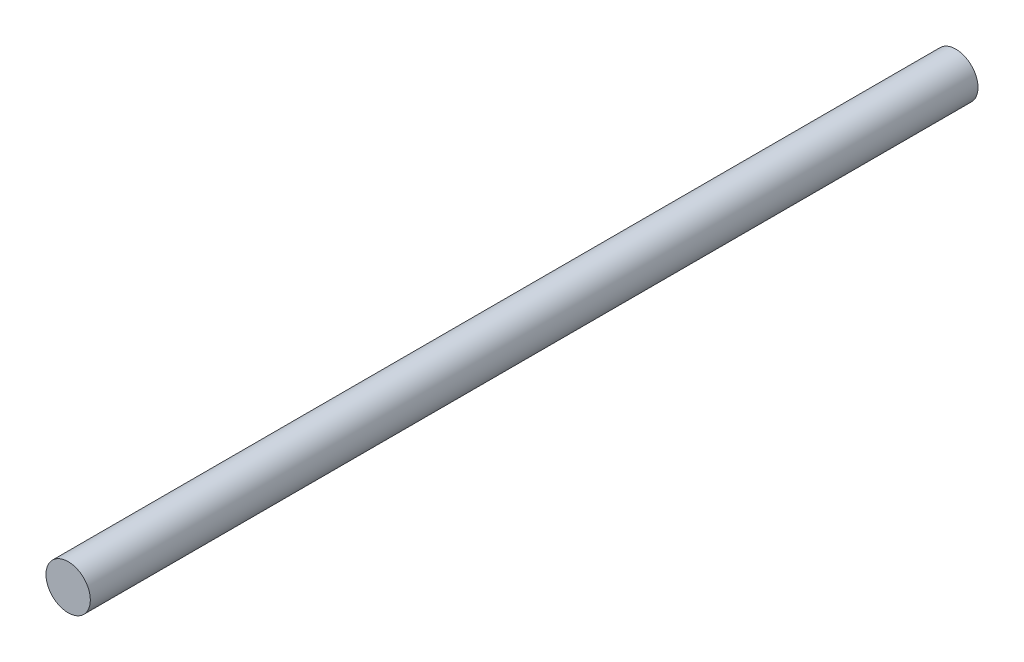
from build123d import *

# Parameters (mm, degrees)
SKETCH1_R           = 1.25
BOSS_EXTRUDE1_DEPTH = 50


with BuildPart() as part:
    # Sketch1 → Boss-Extrude1 (new body)
    with BuildSketch(Plane.XY):
        Circle(SKETCH1_R)
    extrude(amount=BOSS_EXTRUDE1_DEPTH)


solid = part.part
